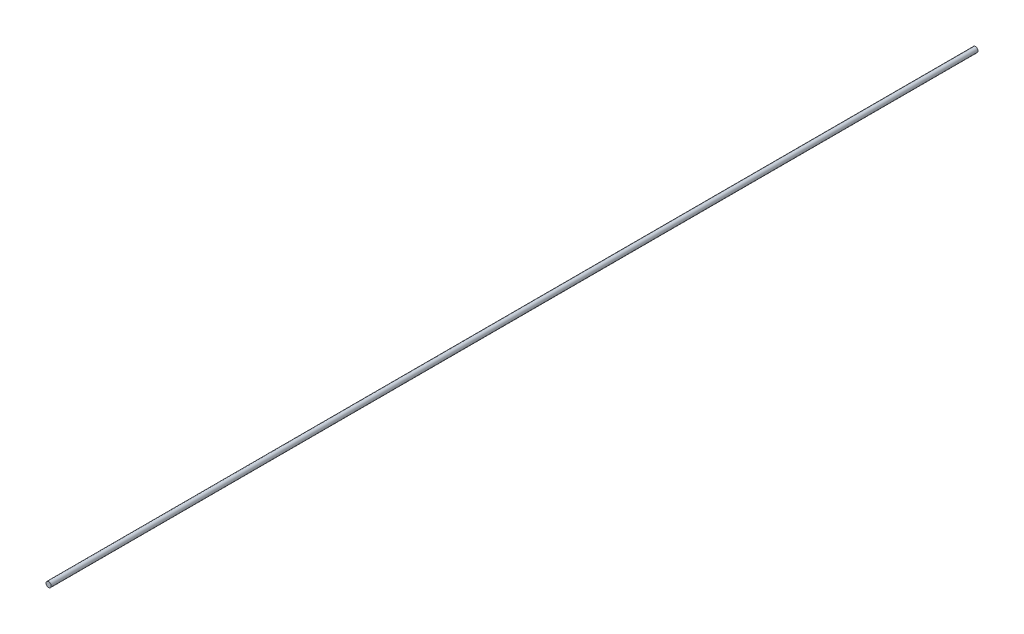
from build123d import *

# Parameters (mm, degrees)
ESBO_O1_W = 5
ESBO_O1_H = 1800


with BuildPart() as part:
    # Esboço1 → Revolução1 (revolve)
    with BuildSketch(Plane.XZ):
        with Locations((2.5, 900)):
            Rectangle(ESBO_O1_W, ESBO_O1_H)
    revolve(axis=Axis((0, 0, 1800), (0, 0, -1)))


solid = part.part
